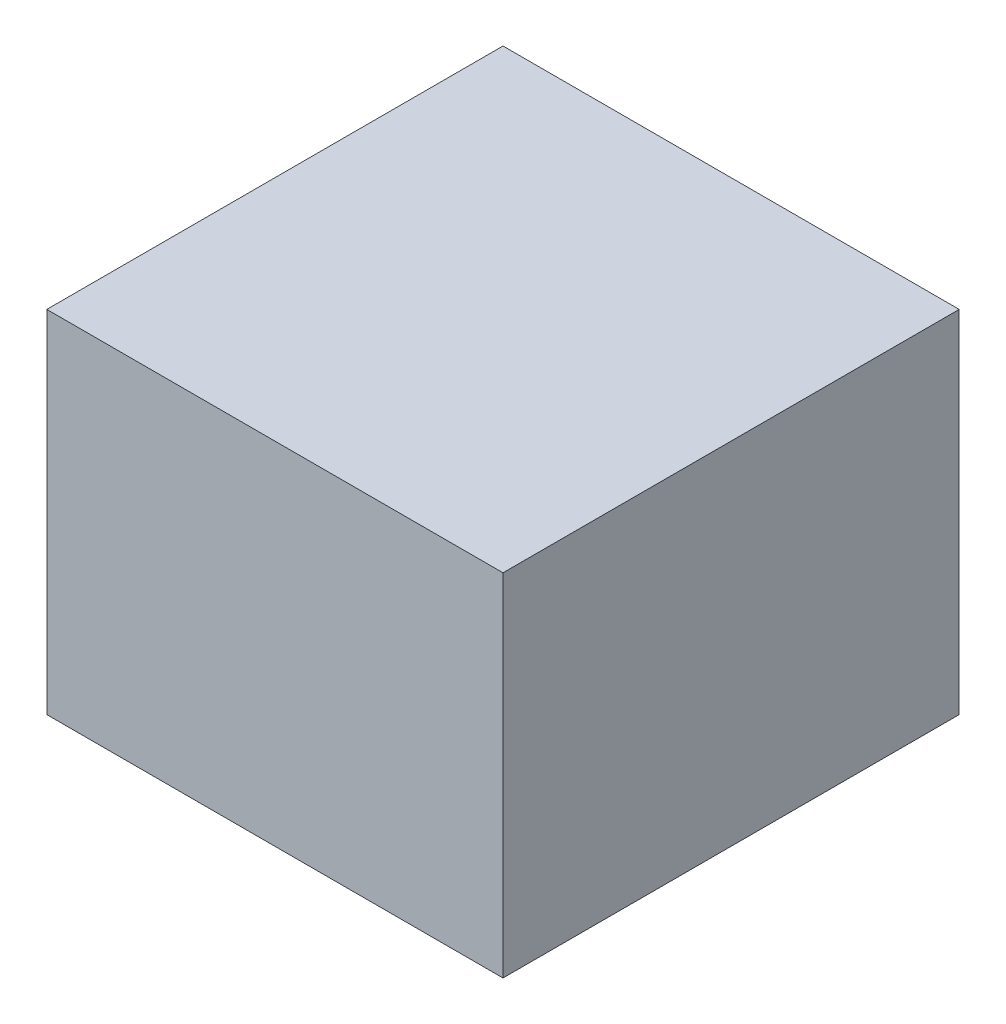
from build123d import *

# Parameters (mm, degrees)
SKETCH1_W           = 45
SKETCH1_H           = 45
BOSS_EXTRUDE1_DEPTH = 7.5
SKETCH2_W           = 65
SKETCH2_H           = 65
BOSS_EXTRUDE2_DEPTH = 50


with BuildPart() as part:
    # Sketch1 → Boss-Extrude1 (new body)
    with BuildSketch(Plane(origin=(0, 0, 0), x_dir=(1, 0, 0), z_dir=(0, 1, 0))):
        Rectangle(SKETCH1_W, SKETCH1_H)
    extrude(amount=BOSS_EXTRUDE1_DEPTH)

    # Sketch2 → Boss-Extrude2 (add)
    with BuildSketch(Plane(origin=(0, 7.5, 0), x_dir=(1, 0, 0), z_dir=(0, 1, 0))):
        Rectangle(SKETCH2_W, SKETCH2_H)
    extrude(amount=BOSS_EXTRUDE2_DEPTH)


solid = part.part
